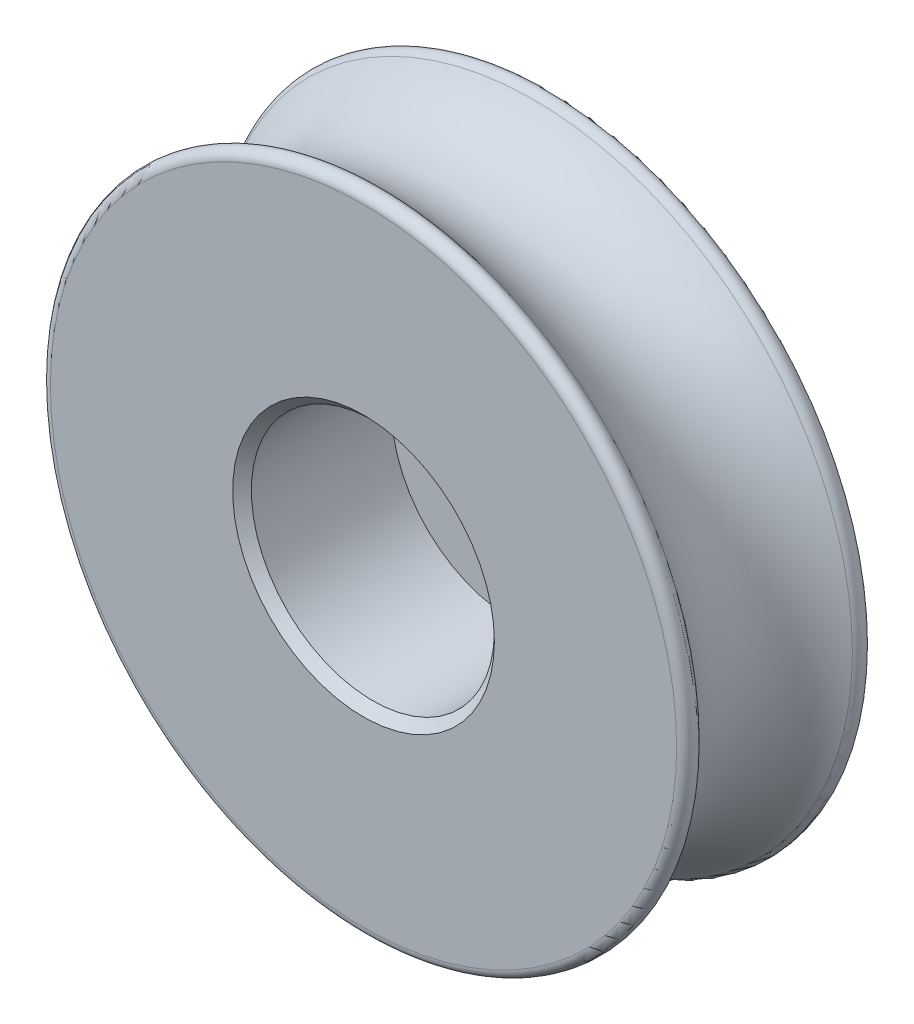
from build123d import *

# Parameters (mm, degrees)
FILLET1_R     = 0.2
CHAMFER2_SIZE = 0.2


with BuildPart() as part:
    # Sketch2 → Revolve1 (revolve)
    with BuildSketch(Plane(origin=(0, 0, 0), x_dir=(1, 0, 0), z_dir=(0, 1, 0))):
        with BuildLine():
            Line((1.1, 4), (7.6, 4))
            ThreePointArc((7.6, 4), (6, 2), (7.6, 0))
            Line((7.6, 0), (2.6, 0))
            Line((2.6, 0), (2.6, 3.2))
            Line((2.6, 3.2), (1.1, 3.2))
            Line((1.1, 3.2), (1.1, 4))
        make_face()
    revolve(axis=Axis((0, 0, 0), (0, 0, -1)))

    # Fillet1
    fillet1_edges = [part.edges().sort_by_distance(p)[0] for p in [
        (-7.6, 0, -4),
        (-7.6, 0, 0),
    ]]
    fillet(fillet1_edges, radius=FILLET1_R)

    # Chamfer2
    chamfer2_edges = [part.edges().sort_by_distance(p)[0] for p in [
        (-1.1, 0, -4),
        (-2.6, 0, 0),
    ]]
    chamfer(chamfer2_edges, length=CHAMFER2_SIZE)


solid = part.part
